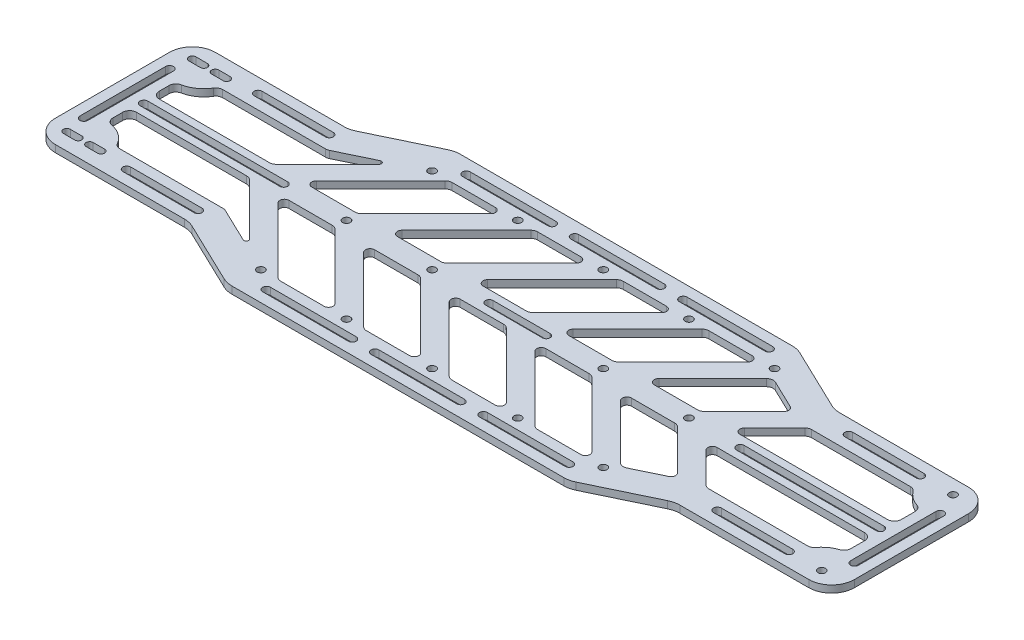
from build123d import *

# Parameters (mm, degrees)
SKETCH1_W            = 355.6
SKETCH1_H            = 101.6
BOSS_EXTRUDE1_DEPTH  = 3.175
M3_CLEARANCE_HOLE2_D = 3.4
CUT_EXTRUDE1_DEPTH   = 4.175
CUT_EXTRUDE3_DEPTH   = 4.175
FILLET1_R            = 10.16
M3_CLEARANCE_HOLE5_D = 3.4
CUT_EXTRUDE4_DEPTH   = 4.175
FILLET2_R            = 2.032
FILLET3_R            = 3.048
FILLET4_R            = 3.048
FILLET5_R            = 3.048
FILLET6_R            = 3.048
FILLET7_R            = 2.032
FILLET8_R            = 1.016
CUT_EXTRUDE5_DEPTH   = 4.175
LPATTERN1_COUNT      = 2
LPATTERN1_PITCH      = 10.16
CUT_EXTRUDE6_DEPTH   = 4.175
CUT_EXTRUDE7_DEPTH   = 4.175
CUT_EXTRUDE8_DEPTH   = 4.175
CUT_EXTRUDE9_DEPTH   = 4.175
CUT_EXTRUDE10_DEPTH  = 4.175


with BuildPart() as part:
    # Sketch1 → Boss-Extrude1 (new body)
    with BuildSketch(Plane(origin=(0, 0, 0), x_dir=(1, 0, 0), z_dir=(0, 1, 0))):
        with Locations((177.8, 50.8)):
            Rectangle(SKETCH1_W, SKETCH1_H)
    extrude(amount=BOSS_EXTRUDE1_DEPTH)

    # M3 Clearance Hole2 (through all)
    with Locations(Plane(origin=(0, 0, 0), x_dir=(-1, 0, 0), z_dir=(0, -1, 0))):
        with Locations((-344.86342, 21.59), (-344.86342, 80.01)):
            Hole(M3_CLEARANCE_HOLE2_D / 2)

    # Sketch7 → Cut-Extrude1 (cut, through all)
    with BuildSketch(Plane.XZ):
        with BuildLine():
            Line((7.62, -21.283803), (12.7, -21.283803))
            ThreePointArc((12.7, -21.283803), (14.276197, -22.86), (12.7, -24.436197))
            Line((12.7, -24.436197), (7.62, -24.436197))
            ThreePointArc((7.62, -24.436197), (6.043803, -22.86), (7.62, -21.283803))
        make_face()
        with BuildLine():
            Line((7.62, -80.316197), (12.7, -80.316197))
            ThreePointArc((12.7, -80.316197), (14.276197, -78.74), (12.7, -77.163803))
            Line((12.7, -77.163803), (7.62, -77.163803))
            ThreePointArc((7.62, -77.163803), (6.043803, -78.74), (7.62, -80.316197))
        make_face()
    cut_extrude1 = extrude(amount=-CUT_EXTRUDE1_DEPTH, mode=Mode.SUBTRACT)

    # Sketch16 → Cut-Extrude3 (cut, through all)
    with BuildSketch(Plane(origin=(0, 3.175, 0), x_dir=(1, 0, 0), z_dir=(0, 1, 0))):
        Polygon((355.6, 15.24), (285.75, 15.24), (254, 0), (355.6, 0), align=None)
        Polygon((69.85, 15.24), (101.6, 0), (0, 0), (0, 15.24), align=None)
        Polygon((0, 86.36), (69.85, 86.36), (101.6, 101.6), (0, 101.6), align=None)
        Polygon((285.75, 86.36), (254, 101.6), (355.6, 101.6), (355.6, 86.36), align=None)
    extrude(amount=-CUT_EXTRUDE3_DEPTH, mode=Mode.SUBTRACT)

    # Fillet1
    fillet1_edges = [part.edges().sort_by_distance(p)[0] for p in [
        (355.6, 1.5875, -15.24),
        (254, 1.5875, 0),
        (285.75, 1.5875, -15.24),
        (0, 1.5875, -15.24),
        (69.85, 1.5875, -15.24),
        (101.6, 1.5875, 0),
        (0, 1.5875, -86.36),
        (101.6, 1.5875, -101.6),
        (69.85, 1.5875, -86.36),
        (355.6, 1.5875, -86.36),
        (285.75, 1.5875, -86.36),
        (254, 1.5875, -101.6),
    ]]
    fillet(fillet1_edges, radius=FILLET1_R)

    # M3 Clearance Hole5 (through all)
    with Locations(Plane(origin=(0, 3.175, 0), x_dir=(1, 0, 0), z_dir=(0, 1, 0))):
        with Locations((104.14, 88.9), (142.24, 88.9), (180.34, 88.9), (218.44, 88.9), (256.54, 88.9), (256.54, 12.7), (218.44, 12.7), (180.34, 12.7), (142.24, 12.7), (104.14, 12.7), (104.14, 50.8), (256.54, 50.8), (142.24, 50.8), (180.34, 50.8), (218.44, 50.8)):
            Hole(M3_CLEARANCE_HOLE5_D / 2)

    # Sketch17 → Cut-Extrude4 (cut, through all)
    with BuildSketch(Plane(origin=(0, 3.175, 0), x_dir=(1, 0, 0), z_dir=(0, 1, 0))):
        Polygon((111.76, 88.9), (78.74, 55.88), (104.14, 55.88), (137.16, 88.9), align=None)
        Polygon((78.74, 45.72), (104.14, 45.72), (137.16, 12.7), (111.76, 12.7), align=None)
        Polygon((175.26, 88.9), (149.86, 88.9), (116.84, 55.88), (142.24, 55.88), align=None)
        Polygon((116.84, 45.72), (142.24, 45.72), (175.26, 12.7), (149.86, 12.7), align=None)
        Polygon((213.36, 88.9), (187.96, 88.9), (154.94, 55.88), (180.34, 55.88), align=None)
        Polygon((154.94, 45.72), (180.34, 45.72), (213.36, 12.7), (187.96, 12.7), align=None)
        Polygon((251.46, 88.9), (226.06, 88.9), (193.04, 55.88), (218.44, 55.88), align=None)
        Polygon((193.04, 45.72), (218.44, 45.72), (251.46, 12.7), (226.06, 12.7), align=None)
        Polygon((260.041081081, 84.781081081), (231.14, 55.88), (256.54, 55.88), (277.203243243, 76.543243243), align=None)
        Polygon((231.14, 45.72), (256.54, 45.72), (277.203243243, 25.056756757), (260.041081081, 16.818918919), align=None)
        with BuildLine():
            Line((287.02, 73.66), (269.24, 55.88))
            Line((269.24, 55.88), (342.9, 55.88))
            Line((342.9, 55.88), (342.9, 67.462690252))
            ThreePointArc((342.9, 67.462690252), (337.679782259, 69.536922668), (333.864897372, 73.66))
            Line((333.864897372, 73.66), (287.02, 73.66))
        make_face()
        with BuildLine():
            Line((269.24, 45.72), (342.9, 45.72))
            Line((342.9, 45.72), (342.9, 34.137309748))
            ThreePointArc((342.9, 34.137309748), (337.679782259, 32.063077332), (333.864897372, 27.94))
            Line((333.864897372, 27.94), (287.02, 27.94))
            Line((287.02, 27.94), (269.24, 45.72))
        make_face()
        with BuildLine():
            Line((12.7, 55.88), (66.04, 55.88))
            Line((66.04, 55.88), (86.36, 76.2))
            Line((86.36, 76.2), (94.047554966, 83.887554966))
            Line((94.047554966, 83.887554966), (72.740148787, 73.66))
            Line((72.740148787, 73.66), (24.339742265, 73.66))
            ThreePointArc((24.339742265, 73.66), (19.65607648, 68.114417663), (12.7, 66.04))
            Line((12.7, 66.04), (12.7, 55.88))
        make_face()
        with BuildLine():
            Line((12.7, 45.72), (66.04, 45.72))
            Line((66.04, 45.72), (86.36, 25.4))
            Line((86.36, 25.4), (94.047554966, 17.712445034))
            Line((94.047554966, 17.712445034), (72.740148787, 27.94))
            Line((72.740148787, 27.94), (24.339742265, 27.94))
            ThreePointArc((24.339742265, 27.94), (19.65607648, 33.485582337), (12.7, 35.56))
            Line((12.7, 35.56), (12.7, 45.72))
        make_face()
    extrude(amount=-CUT_EXTRUDE4_DEPTH, mode=Mode.SUBTRACT)

    # Fillet2
    fillet2_edges = [part.edges().sort_by_distance(p)[0] for p in [
        (137.16, 1.5875, -88.9),
        (78.74, 1.5875, -55.88),
        (78.74, 1.5875, -45.72),
        (137.16, 1.5875, -12.7),
        (116.84, 1.5875, -55.88),
        (175.26, 1.5875, -88.9),
        (116.84, 1.5875, -45.72),
        (175.26, 1.5875, -12.7),
        (154.94, 1.5875, -55.88),
        (213.36, 1.5875, -88.9),
        (154.94, 1.5875, -45.72),
        (213.36, 1.5875, -12.7),
        (193.04, 1.5875, -55.88),
        (251.46, 1.5875, -88.9),
        (193.04, 1.5875, -45.72),
        (251.46, 1.5875, -12.7),
    ]]
    fillet(fillet2_edges, radius=FILLET2_R)

    # Fillet3
    fillet3_edges = [part.edges().sort_by_distance(p)[0] for p in [
        (111.76, 1.5875, -88.9),
        (104.14, 1.5875, -55.88),
        (111.76, 1.5875, -12.7),
        (104.14, 1.5875, -45.72),
        (149.86, 1.5875, -88.9),
        (142.24, 1.5875, -55.88),
        (149.86, 1.5875, -12.7),
        (142.24, 1.5875, -45.72),
        (187.96, 1.5875, -88.9),
        (180.34, 1.5875, -55.88),
        (187.96, 1.5875, -12.7),
        (180.34, 1.5875, -45.72),
        (226.06, 1.5875, -88.9),
        (218.44, 1.5875, -55.88),
        (226.06, 1.5875, -12.7),
        (218.44, 1.5875, -45.72),
    ]]
    fillet(fillet3_edges, radius=FILLET3_R)

    # Fillet4
    fillet4_edges = [part.edges().sort_by_distance(p)[0] for p in [
        (12.7, 1.5875, -55.88),
        (12.7, 1.5875, -66.04),
        (24.339742265, 1.5875, -73.66),
        (72.740148787, 1.5875, -73.66),
        (66.04, 1.5875, -55.88),
    ]]
    fillet(fillet4_edges, radius=FILLET4_R)

    # Fillet5
    fillet5_edges = [part.edges().sort_by_distance(p)[0] for p in [
        (12.7, 1.5875, -35.56),
        (12.7, 1.5875, -45.72),
        (66.04, 1.5875, -45.72),
        (72.740148787, 1.5875, -27.94),
        (24.339742265, 1.5875, -27.94),
    ]]
    fillet(fillet5_edges, radius=FILLET5_R)

    # Fillet6
    fillet6_edges = [part.edges().sort_by_distance(p)[0] for p in [
        (260.041081081, 1.5875, -84.781081081),
        (256.54, 1.5875, -55.88),
        (260.041081081, 1.5875, -16.818918919),
        (256.54, 1.5875, -45.72),
        (287.02, 1.5875, -73.66),
        (333.864897372, 1.5875, -73.66),
        (342.9, 1.5875, -67.462690252),
        (342.9, 1.5875, -55.88),
        (287.02, 1.5875, -27.94),
        (342.9, 1.5875, -45.72),
        (342.9, 1.5875, -34.137309748),
        (333.864897372, 1.5875, -27.94),
    ]]
    fillet(fillet6_edges, radius=FILLET6_R)

    # Fillet7
    fillet7_edges = [part.edges().sort_by_distance(p)[0] for p in [
        (277.203243243, 1.5875, -76.543243243),
        (231.14, 1.5875, -55.88),
        (231.14, 1.5875, -45.72),
        (277.203243243, 1.5875, -25.056756757),
        (269.24, 1.5875, -55.88),
        (269.24, 1.5875, -45.72),
    ]]
    fillet(fillet7_edges, radius=FILLET7_R)

    # Fillet8
    fillet8_edges = [part.edges().sort_by_distance(p)[0] for p in [
        (94.047554966, 1.5875, -83.887554966),
        (94.047554966, 1.5875, -17.712445034),
    ]]
    fillet(fillet8_edges, radius=FILLET8_R)

    # Sketch20 → Cut-Extrude5 (cut, through all)
    with BuildSketch(Plane(origin=(0, 3.175, 0), x_dir=(1, 0, 0), z_dir=(0, 1, 0))):
        with BuildLine():
            Line((167.64, 52.5), (193.04, 52.5))
            ThreePointArc((193.04, 52.5), (194.74, 50.8), (193.04, 49.1))
            Line((193.04, 49.1), (167.64, 49.1))
            ThreePointArc((167.64, 49.1), (165.94, 50.8), (167.64, 52.5))
        make_face()
    extrude(amount=-CUT_EXTRUDE5_DEPTH, mode=Mode.SUBTRACT)

    # LPattern1: Cut-Extrude1 ×2
    with Locations(*[(i * LPATTERN1_PITCH, 0, 0) for i in range(1, LPATTERN1_COUNT)]):
        add(cut_extrude1, mode=Mode.SUBTRACT)

    # Sketch22 → Cut-Extrude6 (cut, through all)
    with BuildSketch(Plane(origin=(0, 3.175, 0), x_dir=(1, 0, 0), z_dir=(0, 1, 0))):
        with BuildLine():
            Line((13.97, 52.55), (76.2, 52.55))
            ThreePointArc((76.2, 52.55), (77.95, 50.8), (76.2, 49.05))
            Line((76.2, 49.05), (13.97, 49.05))
            ThreePointArc((13.97, 49.05), (12.22, 50.8), (13.97, 52.55))
        make_face()
    extrude(amount=-CUT_EXTRUDE6_DEPTH, mode=Mode.SUBTRACT)

    # Sketch23 → Cut-Extrude7 (cut, through all)
    with BuildSketch(Plane(origin=(0, 3.175, 0), x_dir=(1, 0, 0), z_dir=(0, 1, 0))):
        with BuildLine():
            Line((279.4, 52.55), (341.63, 52.55))
            ThreePointArc((341.63, 52.55), (343.38, 50.8), (341.63, 49.05))
            Line((341.63, 49.05), (279.4, 49.05))
            ThreePointArc((279.4, 49.05), (277.65, 50.8), (279.4, 52.55))
        make_face()
    extrude(amount=-CUT_EXTRUDE7_DEPTH, mode=Mode.SUBTRACT)

    # Sketch24 → Cut-Extrude8 (cut, through all)
    with BuildSketch(Plane(origin=(0, 3.175, 0), x_dir=(1, 0, 0), z_dir=(0, 1, 0))):
        with BuildLine():
            Line((8.1, 69.85), (8.1, 31.75))
            ThreePointArc((8.1, 31.75), (6.35, 30), (4.6, 31.75))
            Line((4.6, 31.75), (4.6, 69.85))
            ThreePointArc((4.6, 69.85), (6.35, 71.6), (8.1, 69.85))
        make_face()
        with BuildLine():
            Line((351, 69.85), (351, 31.75))
            ThreePointArc((351, 31.75), (349.25, 30), (347.5, 31.75))
            Line((347.5, 31.75), (347.5, 69.85))
            ThreePointArc((347.5, 69.85), (349.25, 71.6), (351, 69.85))
        make_face()
    extrude(amount=-CUT_EXTRUDE8_DEPTH, mode=Mode.SUBTRACT)

    # Sketch25 → Cut-Extrude9 (cut, through all)
    with BuildSketch(Plane(origin=(0, 3.175, 0), x_dir=(1, 0, 0), z_dir=(0, 1, 0))):
        with BuildLine():
            Line((113.03, 97), (151.13, 97))
            ThreePointArc((151.13, 97), (152.88, 95.25), (151.13, 93.5))
            Line((151.13, 93.5), (113.03, 93.5))
            ThreePointArc((113.03, 93.5), (111.28, 95.25), (113.03, 97))
        make_face()
        with BuildLine():
            Line((161.29, 97), (199.39, 97))
            ThreePointArc((199.39, 97), (201.14, 95.25), (199.39, 93.5))
            Line((199.39, 93.5), (161.29, 93.5))
            ThreePointArc((161.29, 93.5), (159.54, 95.25), (161.29, 97))
        make_face()
        with BuildLine():
            Line((209.55, 97), (247.65, 97))
            ThreePointArc((247.65, 97), (249.4, 95.25), (247.65, 93.5))
            Line((247.65, 93.5), (209.55, 93.5))
            ThreePointArc((209.55, 93.5), (207.8, 95.25), (209.55, 97))
        make_face()
    cut_extrude9 = extrude(amount=-CUT_EXTRUDE9_DEPTH, mode=Mode.SUBTRACT)

    # Mirror1: Cut-Extrude9 across plane
    add(cut_extrude9.mirror(Plane(origin=(0, 0, -50.8), x_dir=(1, 0, 0), z_dir=(0, 0, -1))), mode=Mode.SUBTRACT)

    # Sketch26 → Cut-Extrude10 (cut, through all)
    with BuildSketch(Plane(origin=(0, 3.175, 0), x_dir=(1, 0, 0), z_dir=(0, 1, 0))):
        with BuildLine():
            Line((35.56, 81.76), (67.31, 81.76))
            ThreePointArc((67.31, 81.76), (69.06, 80.01), (67.31, 78.26))
            Line((67.31, 78.26), (35.56, 78.26))
            ThreePointArc((35.56, 78.26), (33.81, 80.01), (35.56, 81.76))
        make_face()
        with BuildLine():
            Line((298.45, 81.76), (330.2, 81.76))
            ThreePointArc((330.2, 81.76), (331.95, 80.01), (330.2, 78.26))
            Line((330.2, 78.26), (298.45, 78.26))
            ThreePointArc((298.45, 78.26), (296.7, 80.01), (298.45, 81.76))
        make_face()
    cut_extrude10 = extrude(amount=-CUT_EXTRUDE10_DEPTH, mode=Mode.SUBTRACT)

    # Mirror2: Cut-Extrude10 across plane
    add(cut_extrude10.mirror(Plane(origin=(0, 0, -50.8), x_dir=(1, 0, 0), z_dir=(0, 0, -1))), mode=Mode.SUBTRACT)


solid = part.part
